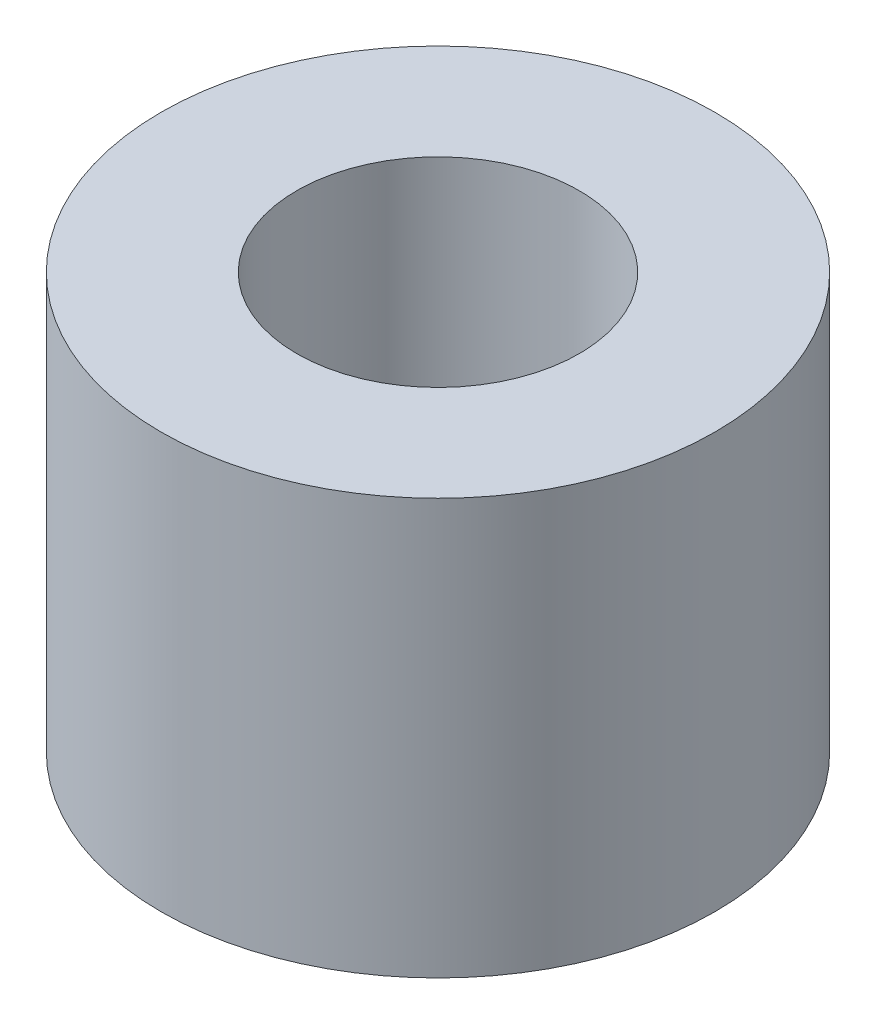
from build123d import *

# Parameters (mm, degrees)
SKIZZE1_R                 = 10
ZYL_DEPTH                 = 15
M12_GEWINDEBOHRUNG1_D     = 10.2
M12_GEWINDEBOHRUNG1_DEPTH = 10
M12_GEWINDEBOHRUNG1_TIP   = 3.064389157


with BuildPart() as part:
    # Skizze1 → Zyl (new body)
    with BuildSketch(Plane(origin=(0, 0, 0), x_dir=(1, 0, 0), z_dir=(0, 1, 0))):
        with Locations(Location((0, 0, 0), (0, 0, 270))):  # turned: the seam where the file's is
            Circle(SKIZZE1_R)
    extrude(amount=ZYL_DEPTH)

    # M12 Gewindebohrung1
    with Locations(Plane(origin=(0, 15, 0), x_dir=(1, 0, 0), z_dir=(0, 1, 0))):
        with Locations((0, 0)):
            Hole(M12_GEWINDEBOHRUNG1_D / 2, depth=M12_GEWINDEBOHRUNG1_DEPTH)
            with Locations((0, 0, -(M12_GEWINDEBOHRUNG1_DEPTH + M12_GEWINDEBOHRUNG1_TIP / 2))):  # 118° drill point
                Cone(0, M12_GEWINDEBOHRUNG1_D / 2, M12_GEWINDEBOHRUNG1_TIP, mode=Mode.SUBTRACT)


solid = part.part
